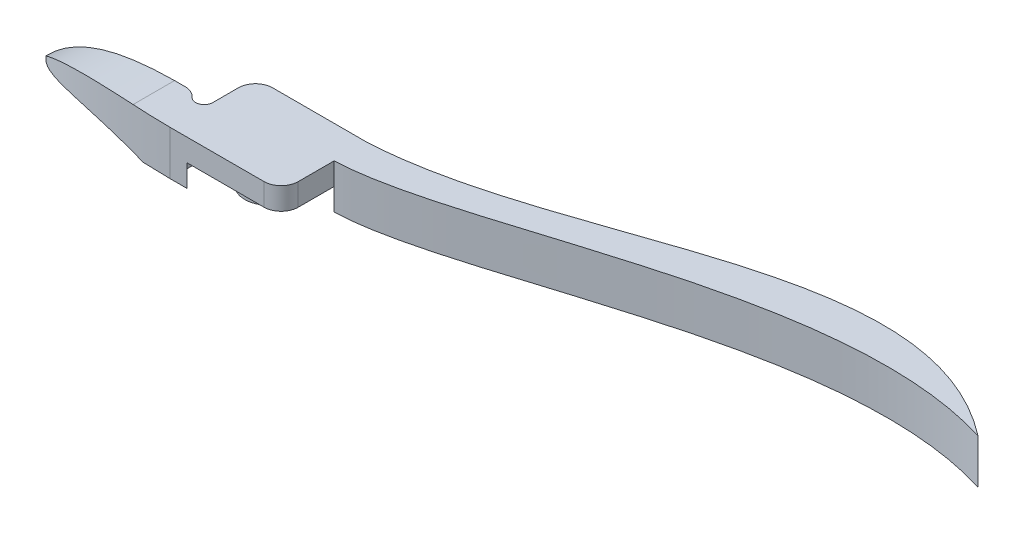
from build123d import *

# Parameters (mm, degrees)
SKETCH1_R                = 3.4925
BOSS_EXTRUDE3_DEPTH      = 3.302
BOSS_EXTRUDE4_DEPTH      = 3.302
BOSS_EXTRUDE5_DEPTH      = 3.302
CUT_EXTRUDE1_REACH       = 8.35
SKETCH1_11_R             = 3.4925
BOSS_EXTRUDE6_DEPTH      = 3.302
BOSS_EXTRUDE6_DEPTH_BACK = 3.302


with BuildPart() as part:
    # Sketch1 → Boss-Extrude3 (new body)
    with BuildSketch(Plane(origin=(0, 0, 0), x_dir=(1, 0, 0), z_dir=(0, 1, 0))):
        with BuildLine():
            ThreePointArc((-10.47160211, -0.846666667), (-11.327855674, -0.22130784), (-12.364806331, 0))
            Line((-12.364806331, 0), (-33.02, 0))
            add(Edge.make_bspline(
                [(-33.02, 0), (-27.473096433, -6.223159861), (-8.255, -6.35)],
                knots=[0, 0, 0, 1, 1, 1], degree=2))
            Line((-8.255, -6.35), (-8.255, -3.81))
            Line((-8.255, -3.81), (-8.255, 0))
            ThreePointArc((-8.255, 0), (-9.071835946, -1.186398896), (-10.47160211, -0.846666667))
        make_face()
        with BuildLine():
            ThreePointArc((5.715, 6.35), (7.511051224, 5.606051224), (8.255, 3.81))
            Line((8.255, 3.81), (8.255, -3.81))
            ThreePointArc((8.255, -3.81), (7.511051224, -5.606051224), (5.715, -6.35))
            Line((5.715, -6.35), (-5.715, -6.35))
            ThreePointArc((-5.715, -6.35), (-7.511051224, -5.606051224), (-8.255, -3.81))
            Line((-8.255, -3.81), (-8.255, 3.81))
            ThreePointArc((-8.255, 3.81), (-7.511051224, 5.606051224), (-5.715, 6.35))
            Line((-5.715, 6.35), (5.715, 6.35))
        make_face()
        with Locations(Location((0, 0, 0), (0, 0, 270))):  # turned: the seam where the file's is
            Circle(SKETCH1_R, mode=Mode.SUBTRACT)
        with BuildLine():
            ThreePointArc((-8.255, -3.81), (-7.511051224, -5.606051224), (-5.715, -6.35))
            Line((-5.715, -6.35), (-8.255, -6.35))
            Line((-8.255, -6.35), (-8.255, -3.81))
        make_face()
        with BuildLine():
            Line((8.255, 3.527942587), (8.255, 1.524))
            add(Edge.make_bspline(
                [(8.255, 1.524), (26.922144182, 2.150849617), (62.646246262, 22.822886738), (91.44, 13.97)],
                knots=[0, 0, 0, 0, 1, 1, 1, 1], degree=3))
            add(Edge.make_bspline(
                [(91.44, 13.97), (66.350363848, 33.352051218), (36.841337127, 7.764653999), (8.255, 6.35)],
                knots=[0, 0, 0, 0, 1, 1, 1, 1], degree=3))
            Line((8.255, 6.35), (8.255, 3.81))
            Line((8.255, 3.81), (8.255, 3.527942587))
        make_face()
        with BuildLine():
            Line((8.255, 6.35), (5.715, 6.35))
            ThreePointArc((5.715, 6.35), (7.511051224, 5.606051224), (8.255, 3.81))
            Line((8.255, 3.81), (8.255, 6.35))
        make_face()
    extrude(amount=BOSS_EXTRUDE3_DEPTH)

    # Sketch1_8 → Boss-Extrude4 (add)
    with BuildSketch(Plane(origin=(0, 0, 0), x_dir=(1, 0, 0), z_dir=(0, 1, 0))):
        with BuildLine():
            Line((8.255, 3.527942587), (8.255, 1.524))
            add(Edge.make_bspline(
                [(8.255, 1.524), (26.922144182, 2.150849617), (62.646246262, 22.822886738), (91.44, 13.97)],
                knots=[0, 0, 0, 0, 1, 1, 1, 1], degree=3))
            add(Edge.make_bspline(
                [(91.44, 13.97), (66.350363848, 33.352051218), (36.841337127, 7.764653999), (8.255, 6.35)],
                knots=[0, 0, 0, 0, 1, 1, 1, 1], degree=3))
            Line((8.255, 6.35), (8.255, 3.81))
            Line((8.255, 3.81), (8.255, 3.527942587))
        make_face()
        with BuildLine():
            Line((8.255, 6.35), (5.715, 6.35))
            ThreePointArc((5.715, 6.35), (7.511051224, 5.606051224), (8.255, 3.81))
            Line((8.255, 3.81), (8.255, 6.35))
        make_face()
    extrude(amount=-BOSS_EXTRUDE4_DEPTH)

    # Sketch1_9 → Boss-Extrude5 (add)
    with BuildSketch(Plane(origin=(0, 0, 0), x_dir=(1, 0, 0), z_dir=(0, 1, 0))):
        with BuildLine():
            ThreePointArc((-10.47160211, -0.846666667), (-11.327855674, -0.22130784), (-12.364806331, 0))
            Line((-12.364806331, 0), (-33.02, 0))
            add(Edge.make_bspline(
                [(-33.02, 0), (-27.473096433, -6.223159861), (-8.255, -6.35)],
                knots=[0, 0, 0, 1, 1, 1], degree=2))
            Line((-8.255, -6.35), (-8.255, -3.81))
            Line((-8.255, -3.81), (-8.255, 0))
            ThreePointArc((-8.255, 0), (-9.071835946, -1.186398896), (-10.47160211, -0.846666667))
        make_face()
        with BuildLine():
            ThreePointArc((-8.255, -3.81), (-7.511051224, -5.606051224), (-5.715, -6.35))
            Line((-5.715, -6.35), (-8.255, -6.35))
            Line((-8.255, -6.35), (-8.255, -3.81))
        make_face()
    extrude(amount=-BOSS_EXTRUDE5_DEPTH)

    # Sketch2 → Cut-Extrude1 (cut, up to next)
    with BuildSketch(Plane.XY, mode=Mode.PRIVATE) as cut_extrude1_sk1:
        with BuildLine():
            Line((-33.02, 3.302), (-33.02, -3.053994927))
            add(Edge.make_bspline(
                [(-33.02, -3.053994927), (-28.519594092, 1.640722514), (-22.101826858, 3.211473856), (-13.921878912, 3.302)],
                knots=[0, 0, 0, 0, 0.941080878, 0.941080878, 0.941080878, 0.941080878], degree=3))
            Line((-13.921878912, 3.302), (-33.02, 3.302))
        make_face()
    cut_extrude1_tool1 = extrude(cut_extrude1_sk1.sketch, amount=CUT_EXTRUDE1_REACH, mode=Mode.PRIVATE) & part.part
    add(cut_extrude1_tool1.solids().sort_by_distance((-28.707051, 1.545014, 0))[0], mode=Mode.SUBTRACT)
    # Sketch2 → Cut-Extrude1 (cut, up to next)
    with BuildSketch(Plane.XY, mode=Mode.PRIVATE) as cut_extrude1_sk2:
        with BuildLine():
            Line((-12.364806331, -3.302), (-33.02, -3.302))
            add(Edge.make_bspline(
                [(-12.364806331, -3.302), (-18.804874471, -1.031483357), (-26.812471442, -0.753963495), (-33.02, -3.302)],
                knots=[0, 0, 0, 0, 1, 1, 1, 1], degree=3))
        make_face()
    cut_extrude1_tool2 = extrude(cut_extrude1_sk2.sketch, amount=CUT_EXTRUDE1_REACH, mode=Mode.PRIVATE) & part.part
    add(cut_extrude1_tool2.solids().sort_by_distance((-22.84596, -2.573969, 0))[0], mode=Mode.SUBTRACT)

    # Sketch1_11 → Boss-Extrude6 (add, two sides)
    with BuildSketch(Plane(origin=(0, 0, 0), x_dir=(1, 0, 0), z_dir=(0, 1, 0))) as boss_extrude6_sk:
        with Locations(Location((0, 0, 0), (0, 0, 270))):  # turned: the seam where the file's is
            Circle(SKETCH1_11_R)
    extrude(amount=BOSS_EXTRUDE6_DEPTH)
    extrude(boss_extrude6_sk.sketch, amount=-BOSS_EXTRUDE6_DEPTH_BACK)


solid = part.part
